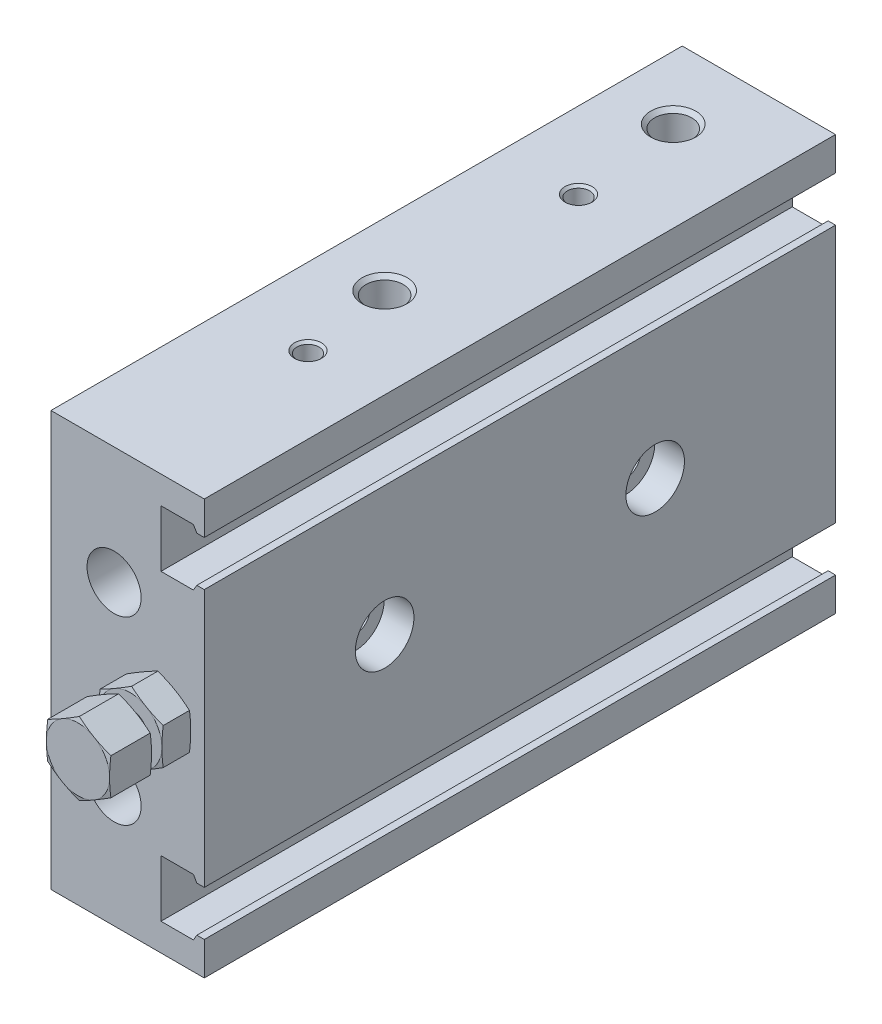
from build123d import *

# Parameters (mm, degrees)
EXTRUDE_1_DEPTH     = 70
SKETCH_18_R         = 8
CUT_EXTRUDE_1_DEPTH = 9


with BuildPart() as part:
    # 草图1 → 凸台-拉伸1 (new body)
    with BuildSketch(Plane.XY):
        Polygon((-7, 23), (-7, -23), (10, -23), (10, -19.3), (9.175277675, -19.3), (8.8, -19.95), (5.2, -19.95), (5.2, -13.65), (8.8, -13.65), (9.175277675, -14.3), (10, -14.3), (10, 14.3), (9.175277675, 14.3), (8.8, 13.65), (5.2, 13.65), (5.2, 19.95), (8.8, 19.95), (9.175277675, 19.3), (10, 19.3), (10, 23), align=None)
    extrude(amount=-EXTRUDE_1_DEPTH)

    # 草图2 → 切除-旋转1 (revolve, cut)
    with BuildSketch(Plane(origin=(0, 0, 0), x_dir=(0, 0, -1), z_dir=(1, 0, 0))):
        Polygon((0, 10), (0, 13), (20, 13), (20, 15), (40, 15), (40, 10), align=None)
    revolve(axis=Axis((0, 10, -40), (0, 0, 1)), mode=Mode.SUBTRACT)

    # 草图3 → 切除-旋转2 (revolve, cut)
    with BuildSketch(Plane(origin=(0, 0, 0), x_dir=(0, 0, -1), z_dir=(1, 0, 0))):
        Polygon((0, -10), (0, -7), (20, -7), (20, -5), (40, -5), (40, -10), align=None)
    revolve(axis=Axis((0, -10, -40), (0, 0, 1)), mode=Mode.SUBTRACT)

    # 草图4 → 切除-旋转3 (revolve, cut)
    with BuildSketch(Plane.XY.offset(-20)):
        Polygon((-7, 0), (-7, 1.7), (6.7, 1.7), (6.7, 3.25), (10, 3.25), (10, 0), align=None)
    revolve(axis=Axis((10, 0, -20), (-1, 0, 0)), mode=Mode.SUBTRACT)

    # 草图5 → 切除-旋转4 (revolve, cut)
    with BuildSketch(Plane.XY.offset(-50)):
        Polygon((-7, 0), (-7, 1.7), (6.7, 1.7), (6.7, 3.25), (10, 3.25), (10, 0), align=None)
    revolve(axis=Axis((10, 0, -50), (-1, 0, 0)), mode=Mode.SUBTRACT)

    # 草图6 → 切除-旋转5 (revolve, cut)
    with BuildSketch(Plane.XY.offset(-20)):
        Polygon((-7, 0), (-7, 2), (-6.621, 1.621), (0, 1.621), (0.935884786, 0), align=None)
    revolve(axis=Axis((0.935884786, 0, -20), (-1, 0, 0)), mode=Mode.SUBTRACT)

    # 草图7 → 切除-旋转6 (revolve, cut)
    with BuildSketch(Plane.XY.offset(-50)):
        Polygon((-7, 0), (-7, 2), (-6.621, 1.621), (0, 1.621), (0.935884786, 0), align=None)
    revolve(axis=Axis((0.935884786, 0, -50), (-1, 0, 0)), mode=Mode.SUBTRACT)

    # 草图8 → 切除-旋转7 (revolve, cut)
    with BuildSketch(Plane(origin=(0, 0, 0), x_dir=(0, 0, -1), z_dir=(1, 0, 0))):
        Polygon((30, 17.306616994), (27.933, 18.5), (27.933, 22.567), (27.5, 23), (30, 23), align=None)
    revolve(axis=Axis((0, 23, -30), (0, -1, 0)), mode=Mode.SUBTRACT)

    # 草图9 → 切除-旋转8 (revolve, cut)
    with BuildSketch(Plane(origin=(0, 0, 0), x_dir=(0, 0, -1), z_dir=(1, 0, 0))):
        Polygon((62, 17.306616994), (59.933, 18.5), (59.933, 22.567), (59.5, 23), (62, 23), align=None)
    revolve(axis=Axis((0, 23, -62), (0, -1, 0)), mode=Mode.SUBTRACT)

    # 草图10 → 切除-旋转9 (revolve, cut)
    with BuildSketch(Plane(origin=(0, 0, 0), x_dir=(0, 0, -1), z_dir=(1, 0, 0))):
        Polygon((30, -23), (27.5, -23), (27.933, -22.567), (27.933, -18.5), (30, -17.306616994), align=None)
    revolve(axis=Axis((0, -17.306616994, -30), (0, -1, 0)), mode=Mode.SUBTRACT)

    # 草图11 → 切除-旋转10 (revolve, cut)
    with BuildSketch(Plane(origin=(0, 0, 0), x_dir=(0, 0, -1), z_dir=(1, 0, 0))):
        Polygon((62, -23), (59.5, -23), (59.933, -22.567), (59.933, -18.5), (62, -17.306616994), align=None)
    revolve(axis=Axis((0, -17.306616994, -62), (0, -1, 0)), mode=Mode.SUBTRACT)

    # 草图12 → 切除-旋转11 (revolve, cut)
    with BuildSketch(Plane(origin=(1.5, 0, 0), x_dir=(0, 0, -1), z_dir=(1, 0, 0))):
        Polygon((20, 17.790147844), (18.7705, 18.5), (18.7705, 22.7295), (18.5, 23), (20, 23), align=None)
    revolve(axis=Axis((1.5, 23, -20), (0, -1, 0)), mode=Mode.SUBTRACT)

    # 草图13 → 切除-旋转12 (revolve, cut)
    with BuildSketch(Plane(origin=(1.5, 0, 0), x_dir=(0, 0, -1), z_dir=(1, 0, 0))):
        Polygon((50, 17.790147844), (48.7705, 18.5), (48.7705, 22.7295), (48.5, 23), (50, 23), align=None)
    revolve(axis=Axis((1.5, 23, -50), (0, -1, 0)), mode=Mode.SUBTRACT)

    # 草图14 → 切除-旋转13 (revolve, cut)
    with BuildSketch(Plane(origin=(1.5, 0, 0), x_dir=(0, 0, -1), z_dir=(1, 0, 0))):
        Polygon((20, -23), (18.5, -23), (18.7705, -22.7295), (18.7705, -18.5), (20, -17.790147844), align=None)
    revolve(axis=Axis((1.5, -17.790147844, -20), (0, -1, 0)), mode=Mode.SUBTRACT)

    # 草图15 → 切除-旋转14 (revolve, cut)
    with BuildSketch(Plane(origin=(1.5, 0, 0), x_dir=(0, 0, -1), z_dir=(1, 0, 0))):
        Polygon((50, -23), (48.5, -23), (48.7705, -22.7295), (48.7705, -18.5), (50, -17.790147844), align=None)
    revolve(axis=Axis((1.5, -17.790147844, -50), (0, -1, 0)), mode=Mode.SUBTRACT)

    # 草图16 → 旋转1 (revolve)
    with BuildSketch(Plane(origin=(5, 0, 0), x_dir=(0, 0, -1), z_dir=(1, 0, 0))):
        Polygon((-3.2, 0), (-3.2, 3.5), (-2.262177826, 7), (-0.937822174, 7), (0, 3.5), (0, 0), align=None)
    revolve(axis=Axis((5, 0, 0), (0, 0, 1)))

    # 草图17 → 旋转2 (revolve)
    with BuildSketch(Plane(origin=(5, 0, 0), x_dir=(0, 0, -1), z_dir=(1, 0, 0))):
        Polygon((-9, 0), (-9, 3.5), (-8.062177826, 7), (-5.287822174, 7), (-4.35, 3.5), (-4.35, 2), (-3.2, 2), (-3.2, 0), align=None)
    revolve(axis=Axis((5, 0, 3.2), (0, 0, 1)))

    # 草图18 → 切除-拉伸1 (cut)
    with BuildSketch(Plane.XY):
        with Locations((5, 0)):
            Circle(SKETCH_18_R)
        Polygon((1.5, 2.020725942), (1.5, -2.020725942), (5, -4.041451884), (8.5, -2.020725942), (8.5, 2.020725942), (5, 4.041451884), align=None, mode=Mode.SUBTRACT)
    extrude(amount=CUT_EXTRUDE_1_DEPTH, mode=Mode.SUBTRACT)


solid = part.part
